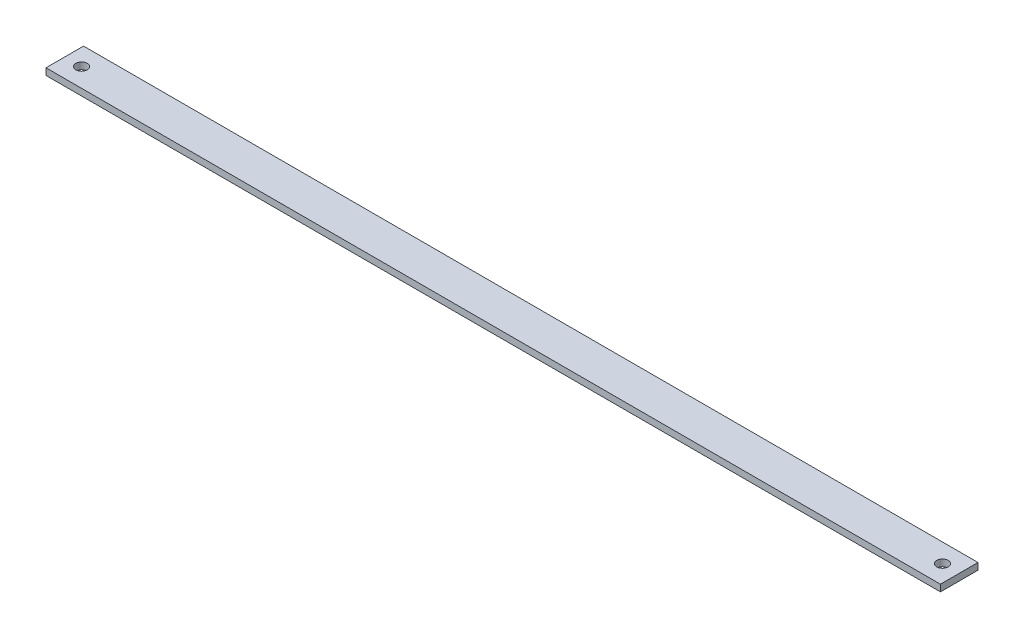
from build123d import *

# Parameters (mm, degrees)
SKETCH1_W           = 400
SKETCH1_H           = 16.8
SKETCH1_R           = 2.55
BOSS_EXTRUDE1_DEPTH = 3


with BuildPart() as part:
    # Sketch1 → Boss-Extrude1 (new body)
    with BuildSketch(Plane(origin=(0, 0, 0), x_dir=(1, 0, 0), z_dir=(0, 1, 0))):
        Rectangle(SKETCH1_W, SKETCH1_H)
        with Locations((-192.5, 0)):
            Circle(SKETCH1_R, mode=Mode.SUBTRACT)
        with Locations((192.5, 0)):
            Circle(SKETCH1_R, mode=Mode.SUBTRACT)
    extrude(amount=BOSS_EXTRUDE1_DEPTH)


solid = part.part
